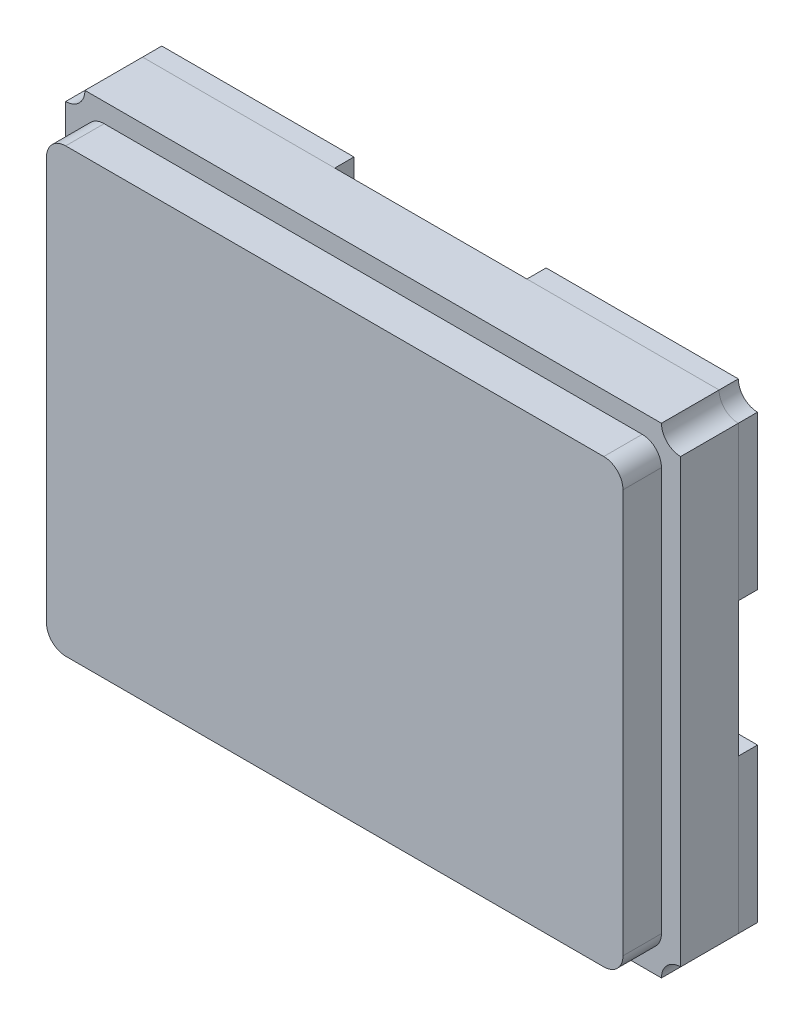
from build123d import *

# Parameters (mm, degrees)
BOSS_EXTRUDE1_DEPTH   = 0.3
SKETCH2_W             = 3
SKETCH2_H             = 2.3
BOSS_EXTRUDE2_DEPTH   = 0.2
FILLET1_R             = 0.1
BOSS_EXTRUDE3_DEPTH   = 0.1
BOSS_EXTRUDE3_2_DEPTH = 0.1
BOSS_EXTRUDE3_3_DEPTH = 0.1
BOSS_EXTRUDE3_4_DEPTH = 0.1


with BuildPart() as part:
    # Sketch1 → Boss-Extrude1 (new body)
    with BuildSketch(Plane.XY):
        with BuildLine():
            Line((0.1, 0), (3.1, 0))
            ThreePointArc((3.1, 0), (3.129289322, 0.070710678), (3.2, 0.1))
            Line((3.2, 0.1), (3.2, 2.4))
            ThreePointArc((3.2, 2.4), (3.129289322, 2.429289322), (3.1, 2.5))
            Line((3.1, 2.5), (0.1, 2.5))
            ThreePointArc((0.1, 2.5), (0.070710678, 2.429289322), (0, 2.4))
            Line((0, 2.4), (0, 0.1))
            ThreePointArc((0, 0.1), (0.070710678, 0.070710678), (0.1, 0))
        make_face()
    extrude(amount=BOSS_EXTRUDE1_DEPTH)

    # Sketch2 → Boss-Extrude2 (add)
    with BuildSketch(Plane.XY.offset(0.3)):
        with Locations((1.6, 1.25)):
            Rectangle(SKETCH2_W, SKETCH2_H)
    extrude(amount=BOSS_EXTRUDE2_DEPTH)

    # Fillet1
    fillet1_edges = [part.edges().sort_by_distance(p)[0] for p in [
        (0.1, 2.4, 0.4),
        (0.1, 0.1, 0.4),
        (3.1, 0.1, 0.4),
        (3.1, 2.4, 0.4),
    ]]
    fillet(fillet1_edges, radius=FILLET1_R)


with BuildPart() as body_2:
    # Sketch3 → Boss-Extrude3 (new body)
    with BuildSketch(Plane(origin=(0, 0, 0), x_dir=(-1, 0, 0), z_dir=(0, 0, -1))):
        with BuildLine():
            Line((-2.1, 2.5), (-3.1, 2.5))
            ThreePointArc((-3.1, 2.5), (-3.129289322, 2.429289322), (-3.2, 2.4))
            Line((-3.2, 2.4), (-3.2, 1.6))
            Line((-3.2, 1.6), (-2.1, 1.6))
            Line((-2.1, 1.6), (-2.1, 2.5))
        make_face()
    extrude(amount=BOSS_EXTRUDE3_DEPTH)


with BuildPart() as body_3:
    # Sketch3 → Boss-Extrude3 2 (new body)
    with BuildSketch(Plane(origin=(0, 0, 0), x_dir=(-1, 0, 0), z_dir=(0, 0, -1))):
        with BuildLine():
            Line((-1.1, 2.5), (-0.1, 2.5))
            ThreePointArc((-0.1, 2.5), (-0.070710678, 2.429289322), (0, 2.4))
            Line((0, 2.4), (0, 1.6))
            Line((0, 1.6), (-1.1, 1.6))
            Line((-1.1, 1.6), (-1.1, 2.5))
        make_face()
    extrude(amount=BOSS_EXTRUDE3_2_DEPTH)


with BuildPart() as body_4:
    # Sketch3 → Boss-Extrude3 3 (new body)
    with BuildSketch(Plane(origin=(0, 0, 0), x_dir=(-1, 0, 0), z_dir=(0, 0, -1))):
        with BuildLine():
            Line((-1.1, 0.9), (0, 0.9))
            Line((0, 0.9), (0, 0.1))
            ThreePointArc((0, 0.1), (-0.070710678, 0.070710678), (-0.1, 0))
            Line((-0.1, 0), (-1.1, 0))
            Line((-1.1, 0), (-1.1, 0.9))
        make_face()
    extrude(amount=BOSS_EXTRUDE3_3_DEPTH)


with BuildPart() as body_5:
    # Sketch3 → Boss-Extrude3 4 (new body)
    with BuildSketch(Plane(origin=(0, 0, 0), x_dir=(-1, 0, 0), z_dir=(0, 0, -1))):
        with BuildLine():
            Line((-2.1, 0.9), (-3.2, 0.9))
            Line((-3.2, 0.9), (-3.2, 0.1))
            ThreePointArc((-3.2, 0.1), (-3.129289322, 0.070710678), (-3.1, 0))
            Line((-3.1, 0), (-2.1, 0))
            Line((-2.1, 0), (-2.1, 0.9))
        make_face()
    extrude(amount=BOSS_EXTRUDE3_4_DEPTH)


solid = Compound([part.part, body_2.part, body_3.part, body_4.part, body_5.part])
